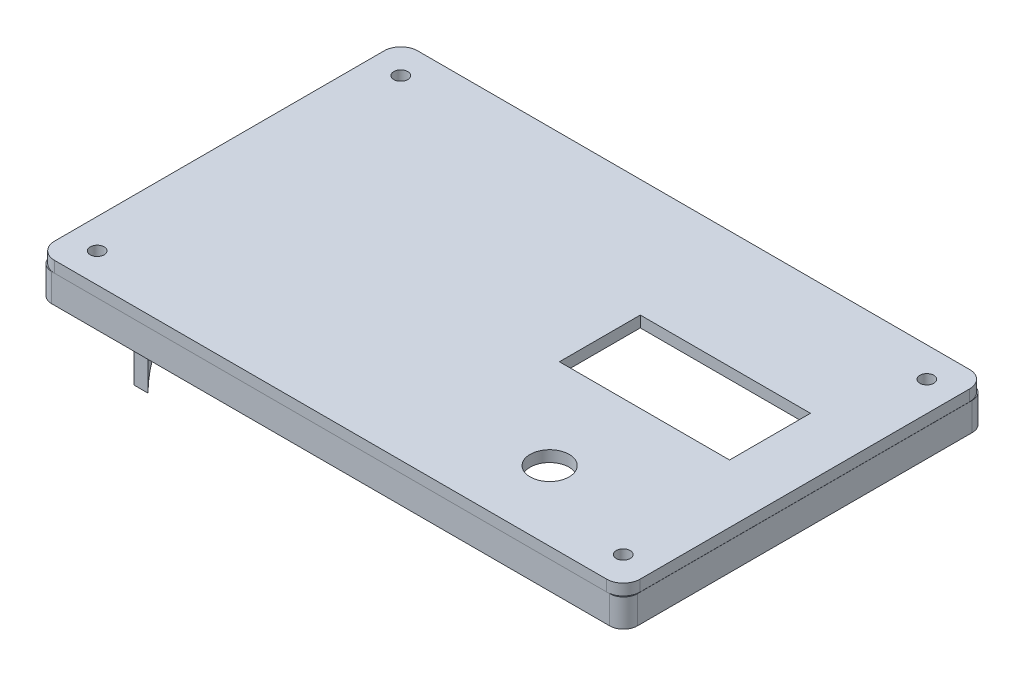
from build123d import *

# Parameters (mm, degrees)
SKETCH_1_R          = 1.25
EXTRUDE_1_DEPTH     = 5
SKETCH_2_W          = 2.5
SKETCH_2_H          = 30.5
EXTRUDE_2_DEPTH     = 22.5
CUT_EXTRUDE_1_REACH = 107
SKETCH_4_R          = 3.5
SKETCH_4_R_2        = 1.25
SKETCH_4_W          = 30.5
SKETCH_4_H          = 14.5
EXTRUDE_3_DEPTH     = 2


with BuildPart() as part:
    # Эскиз1 → Бобышка-Вытянуть1 (new body)
    with BuildSketch(Plane(origin=(0, 0, 0), x_dir=(1, 0, 0), z_dir=(0, 1, 0))):
        with BuildLine():
            Line((-50, 32.5), (50, 32.5))
            ThreePointArc((50, 32.5), (51.767766953, 31.767766953), (52.5, 30))
            Line((52.5, 30), (52.5, -30))
            ThreePointArc((52.5, -30), (51.767766953, -31.767766953), (50, -32.5))
            Line((50, -32.5), (-50, -32.5))
            ThreePointArc((-50, -32.5), (-51.767766953, -31.767766953), (-52.5, -30))
            Line((-52.5, -30), (-52.5, -27.5))
            Line((-52.5, -27.5), (-52.5, 27.5))
            Line((-52.5, 27.5), (-52.5, 30))
            ThreePointArc((-52.5, 30), (-51.767766953, 31.767766953), (-50, 32.5))
        make_face()
        with Locations((-47.144457485, 27.207649218)):
            Circle(SKETCH_1_R, mode=Mode.SUBTRACT)
        with Locations((47.144457485, -27.207649218)):
            Circle(SKETCH_1_R, mode=Mode.SUBTRACT)
        with Locations((47.144457485, 27.207649218)):
            Circle(SKETCH_1_R, mode=Mode.SUBTRACT)
        with Locations((-47.144457485, -27.207649218)):
            Circle(SKETCH_1_R, mode=Mode.SUBTRACT)
        with BuildLine():
            Line((-40.944886513, 30), (40.944886513, 30))
            ThreePointArc((40.944886513, 30), (42.446070129, 29.321532349), (42.928749224, 27.74644775))
            ThreePointArc((42.928749224, 27.74644775), (44.154618836, 24.187158388), (47.726226395, 22.997655757))
            ThreePointArc((47.726226395, 22.997655757), (49.313859351, 22.524386076), (50, 21.016482364))
            Line((50, 21.016482364), (50, -21.016482364))
            ThreePointArc((50, -21.016482364), (49.313859351, -22.524386076), (47.726226395, -22.997655757))
            ThreePointArc((47.726226395, -22.997655757), (44.154618836, -24.187158388), (42.928749224, -27.74644775))
            ThreePointArc((42.928749224, -27.74644775), (42.446070129, -29.321532349), (40.944886513, -30))
            Line((40.944886513, -30), (-40.944886513, -30))
            ThreePointArc((-40.944886513, -30), (-42.446070129, -29.321532349), (-42.928749224, -27.74644775))
            ThreePointArc((-42.928749224, -27.74644775), (-44.154618836, -24.187158388), (-47.726226395, -22.997655757))
            ThreePointArc((-47.726226395, -22.997655757), (-49.313859351, -22.524386076), (-50, -21.016482364))
            Line((-50, -21.016482364), (-50, 21.016482364))
            ThreePointArc((-50, 21.016482364), (-49.313859351, 22.524386076), (-47.726226395, 22.997655757))
            ThreePointArc((-47.726226395, 22.997655757), (-44.154618836, 24.187158388), (-42.928749224, 27.74644775))
            ThreePointArc((-42.928749224, 27.74644775), (-42.446070129, 29.321532349), (-40.944886513, 30))
        make_face(mode=Mode.SUBTRACT)
    extrude(amount=EXTRUDE_1_DEPTH)

    # Эскиз2 → Бобышка-Вытянуть2 (add)
    with BuildSketch(Plane.XZ):
        with Locations((-51.25, 0)):
            Rectangle(SKETCH_2_W, SKETCH_2_H)
    extrude(amount=EXTRUDE_2_DEPTH)

    # Эскиз3 → Вырез-Вытянуть1 (cut, up to next)
    with BuildSketch(Plane.ZY.offset(52.5), mode=Mode.PRIVATE) as cut_extrude_1_sk1:
        with BuildLine():
            Line((-15.25, -22.5), (15.25, -22.5))
            ThreePointArc((15.25, -22.5), (0, -7.25), (-15.25, -22.5))
        make_face()
    cut_extrude_1_tool1 = extrude(cut_extrude_1_sk1.sketch, amount=-CUT_EXTRUDE_1_REACH, mode=Mode.PRIVATE) & part.part
    add(cut_extrude_1_tool1.solids().sort_by_distance((-52.5, -16.027699, 0))[0], mode=Mode.SUBTRACT)

    # Эскиз4 → Бобышка-Вытянуть3 (add)
    with BuildSketch(Plane(origin=(0, 5, 0), x_dir=(1, 0, 0), z_dir=(0, 1, 0))):
        with BuildLine():
            Line((-49.4756814, 32.562921498), (49.4756814, 32.562921498))
            ThreePointArc((49.4756814, 32.562921498), (51.597001743, 31.684241842), (52.4756814, 29.562921498))
            Line((52.4756814, 29.562921498), (52.4756814, -29.509131029))
            ThreePointArc((52.4756814, -29.509131029), (51.597001743, -31.630451373), (49.4756814, -32.509131029))
            Line((49.4756814, -32.509131029), (-49.4756814, -32.509131029))
            ThreePointArc((-49.4756814, -32.509131029), (-51.597001743, -31.630451373), (-52.4756814, -29.509131029))
            Line((-52.4756814, -29.509131029), (-52.4756814, 29.562921498))
            ThreePointArc((-52.4756814, 29.562921498), (-51.597001743, 31.684241842), (-49.4756814, 32.562921498))
        make_face()
        with Locations((26.75, -20)):
            Circle(SKETCH_4_R, mode=Mode.SUBTRACT)
        with Locations((-47.144457485, 27.207649218)):
            Circle(SKETCH_4_R_2, mode=Mode.SUBTRACT)
        with Locations((47.144457485, 27.207649218)):
            Circle(SKETCH_4_R_2, mode=Mode.SUBTRACT)
        with Locations((47.144457485, -27.207649218)):
            Circle(SKETCH_4_R_2, mode=Mode.SUBTRACT)
        with Locations((-47.144457485, -27.207649218)):
            Circle(SKETCH_4_R_2, mode=Mode.SUBTRACT)
        with Locations((26.75, 4.25)):
            Rectangle(SKETCH_4_W, SKETCH_4_H, mode=Mode.SUBTRACT)
    extrude(amount=EXTRUDE_3_DEPTH)


solid = part.part
